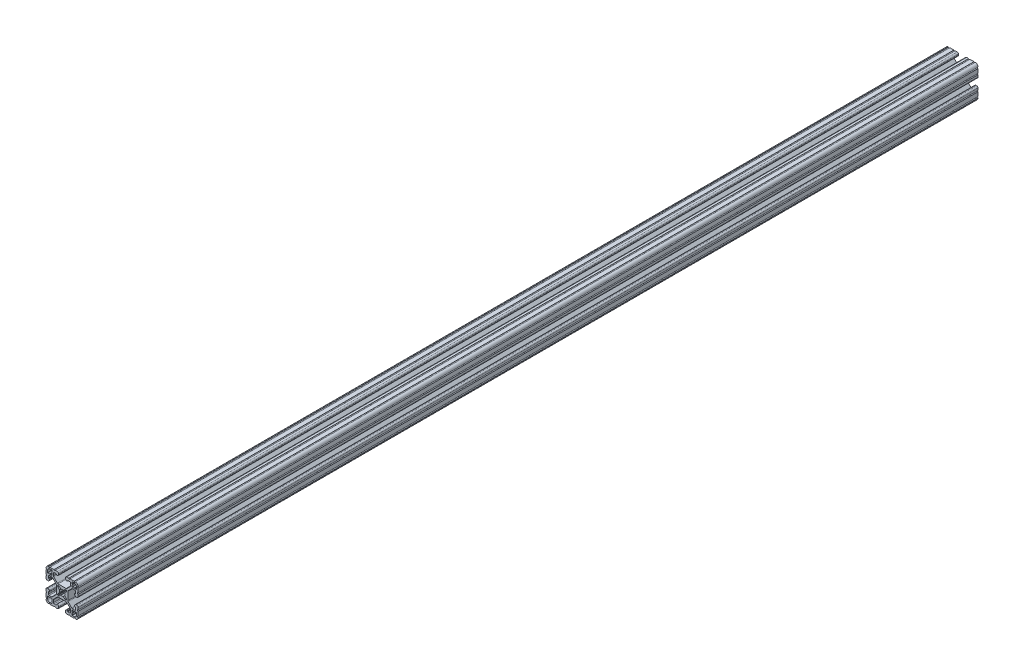
from build123d import *

# Parameters (mm, degrees)
BOSS_EXTRUDE1_DEPTH = 1066.8


with BuildPart() as part:
    # Sketch1 → Boss-Extrude1 (new body)
    with BuildSketch(Plane(origin=(0, 0, -2322.576), x_dir=(-1, 0, 0), z_dir=(0, 0, -1))):
        with BuildLine():
            Line((19.05, -14.325600033), (19.05, -9.4996))
            ThreePointArc((19.05, -9.4996), (18.288, -8.7376), (19.05, -7.9756))
            Line((19.05, -7.9756), (19.05, -5.6388))
            ThreePointArc((19.05, -5.6388), (18.588751759, -4.525248241), (17.4752, -4.064))
            Line((17.4752, -4.064), (16.5608, -4.064))
            ThreePointArc((16.5608, -4.064), (15.447248241, -4.525248241), (14.986, -5.6388))
            Line((14.986, -5.6388), (14.986, -6.350014224))
            ThreePointArc((14.986, -6.350014224), (15.097592316, -6.619421908), (15.367, -6.731014224))
            Line((15.367, -6.731014224), (15.6972, -6.731014224))
            ThreePointArc((15.6972, -6.731014224), (15.966607684, -6.84260654), (16.0782, -7.112014224))
            Line((16.0782, -7.112014224), (16.0782, -9.398014224))
            ThreePointArc((16.0782, -9.398014224), (15.817817928, -10.026632152), (15.1892, -10.287014224))
            Line((15.1892, -10.287014224), (12.375630013, -10.287014224))
            ThreePointArc((12.375630013, -10.287014224), (11.889622054, -10.19034123), (11.477604401, -9.915039836))
            Line((11.477604401, -9.915039836), (7.115699788, -5.553135223))
            ThreePointArc((7.115699788, -5.553135223), (6.840398394, -5.14111757), (6.7437254, -4.655109611))
            Line((6.7437254, -4.655109611), (6.7437254, 4.655109611))
            ThreePointArc((6.7437254, 4.655109611), (6.840398394, 5.14111757), (7.115699788, 5.553135223))
            Line((7.115699788, 5.553135223), (11.477604401, 9.915039836))
            ThreePointArc((11.477604401, 9.915039836), (11.889622054, 10.19034123), (12.375630013, 10.287014224))
            Line((12.375630013, 10.287014224), (15.1892, 10.287014224))
            ThreePointArc((15.1892, 10.287014224), (15.817817928, 10.026632152), (16.0782, 9.398014224))
            Line((16.0782, 9.398014224), (16.0782, 7.112014224))
            ThreePointArc((16.0782, 7.112014224), (15.966607684, 6.84260654), (15.6972, 6.731014224))
            Line((15.6972, 6.731014224), (15.367, 6.731014224))
            ThreePointArc((15.367, 6.731014224), (15.097592316, 6.619421908), (14.986, 6.350014224))
            Line((14.986, 6.350014224), (14.986, 5.6388))
            ThreePointArc((14.986, 5.6388), (15.447248241, 4.525248241), (16.5608, 4.064))
            Line((16.5608, 4.064), (17.4752, 4.064))
            ThreePointArc((17.4752, 4.064), (18.588751759, 4.525248241), (19.05, 5.6388))
            Line((19.05, 5.6388), (19.05, 7.9756))
            ThreePointArc((19.05, 7.9756), (18.288, 8.7376), (19.05, 9.4996))
            Line((19.05, 9.4996), (19.05, 14.325599984))
            ThreePointArc((19.05, 14.325599984), (18.287999986, 15.087549208), (19.049898416, 15.849600009))
            ThreePointArc((19.049898416, 15.849600009), (18.120064036, 18.120064058), (15.849599977, 19.049898414))
            ThreePointArc((15.849599977, 19.049898414), (15.0875492, 18.288000035), (14.325600017, 19.050000016))
            Line((14.325600017, 19.050000016), (9.499600001, 19.050000016))
            ThreePointArc((9.499600001, 19.050000016), (8.737600001, 18.288000016), (7.975600001, 19.050000016))
            Line((7.975600001, 19.050000016), (5.638800016, 19.050000016))
            ThreePointArc((5.638800016, 19.050000016), (4.525248257, 18.588751775), (4.064000016, 17.475200016))
            Line((4.064000016, 17.475200016), (4.064000016, 16.5608))
            ThreePointArc((4.064000016, 16.5608), (4.525248257, 15.447248241), (5.638800016, 14.986))
            Line((5.638800016, 14.986), (6.350014224, 14.986))
            ThreePointArc((6.350014224, 14.986), (6.619421908, 15.097592316), (6.731014224, 15.367))
            Line((6.731014224, 15.367), (6.731014224, 15.6972))
            ThreePointArc((6.731014224, 15.6972), (6.84260654, 15.966607684), (7.112014224, 16.0782))
            Line((7.112014224, 16.0782), (9.398014224, 16.0782))
            ThreePointArc((9.398014224, 16.0782), (10.026632152, 15.817817928), (10.287014224, 15.1892))
            Line((10.287014224, 15.1892), (10.287014224, 12.375630013))
            ThreePointArc((10.287014224, 12.375630013), (10.19034123, 11.889622054), (9.915039836, 11.477604401))
            Line((9.915039836, 11.477604401), (5.553135223, 7.115699788))
            ThreePointArc((5.553135223, 7.115699788), (5.14111757, 6.840398394), (4.655109611, 6.7437254))
            Line((4.655109611, 6.7437254), (-4.655109611, 6.7437254))
            ThreePointArc((-4.655109611, 6.7437254), (-5.14111757, 6.840398394), (-5.553135223, 7.115699788))
            Line((-5.553135223, 7.115699788), (-9.915039836, 11.477604401))
            ThreePointArc((-9.915039836, 11.477604401), (-10.19034123, 11.889622054), (-10.287014224, 12.375630013))
            Line((-10.287014224, 12.375630013), (-10.287014224, 15.1892))
            ThreePointArc((-10.287014224, 15.1892), (-10.026632152, 15.817817928), (-9.398014224, 16.0782))
            Line((-9.398014224, 16.0782), (-7.112014224, 16.0782))
            ThreePointArc((-7.112014224, 16.0782), (-6.84260654, 15.966607684), (-6.731014224, 15.6972))
            Line((-6.731014224, 15.6972), (-6.731014224, 15.367))
            ThreePointArc((-6.731014224, 15.367), (-6.619421908, 15.097592316), (-6.350014224, 14.986))
            Line((-6.350014224, 14.986), (-5.638799984, 14.986))
            ThreePointArc((-5.638799984, 14.986), (-4.525248225, 15.447248241), (-4.063999984, 16.5608))
            Line((-4.063999984, 16.5608), (-4.063999984, 17.475200016))
            ThreePointArc((-4.063999984, 17.475200016), (-4.525248225, 18.588751775), (-5.638799984, 19.050000016))
            Line((-5.638799984, 19.050000016), (-7.975599999, 19.050000016))
            ThreePointArc((-7.975599999, 19.050000016), (-8.737599999, 18.288000016), (-9.499599999, 19.050000016))
            Line((-9.499599999, 19.050000016), (-14.325599999, 19.050000016))
            ThreePointArc((-14.325599999, 19.050000016), (-15.087549199, 18.288000018), (-15.849599993, 19.049898416))
            ThreePointArc((-15.849599993, 19.049898416), (-18.120064042, 18.120064036), (-19.049898398, 15.849599976))
            ThreePointArc((-19.049898398, 15.849599976), (-18.288000019, 15.087549199), (-19.05, 14.325600017))
            Line((-19.05, 14.325600017), (-19.05, 9.4996))
            ThreePointArc((-19.05, 9.4996), (-18.288, 8.7376), (-19.05, 7.9756))
            Line((-19.05, 7.9756), (-19.05, 5.6388))
            ThreePointArc((-19.05, 5.6388), (-18.588751759, 4.525248241), (-17.4752, 4.064))
            Line((-17.4752, 4.064), (-16.5608, 4.064))
            ThreePointArc((-16.5608, 4.064), (-15.447248241, 4.525248241), (-14.986, 5.6388))
            Line((-14.986, 5.6388), (-14.986, 6.350014224))
            ThreePointArc((-14.986, 6.350014224), (-15.097592316, 6.619421908), (-15.367, 6.731014224))
            Line((-15.367, 6.731014224), (-15.6972, 6.731014224))
            ThreePointArc((-15.6972, 6.731014224), (-15.966607684, 6.84260654), (-16.0782, 7.112014224))
            Line((-16.0782, 7.112014224), (-16.0782, 9.398014224))
            ThreePointArc((-16.0782, 9.398014224), (-15.817817928, 10.026632152), (-15.1892, 10.287014224))
            Line((-15.1892, 10.287014224), (-12.375630013, 10.287014224))
            ThreePointArc((-12.375630013, 10.287014224), (-11.889622054, 10.19034123), (-11.477604401, 9.915039836))
            Line((-11.477604401, 9.915039836), (-7.115699788, 5.553135223))
            ThreePointArc((-7.115699788, 5.553135223), (-6.840398394, 5.14111757), (-6.7437254, 4.655109611))
            Line((-6.7437254, 4.655109611), (-6.7437254, -4.655109611))
            ThreePointArc((-6.7437254, -4.655109611), (-6.840398394, -5.14111757), (-7.115699788, -5.553135223))
            Line((-7.115699788, -5.553135223), (-11.477604401, -9.915039836))
            ThreePointArc((-11.477604401, -9.915039836), (-11.889622054, -10.19034123), (-12.375630013, -10.287014224))
            Line((-12.375630013, -10.287014224), (-15.1892, -10.287014224))
            ThreePointArc((-15.1892, -10.287014224), (-15.817817928, -10.026632152), (-16.0782, -9.398014224))
            Line((-16.0782, -9.398014224), (-16.0782, -7.112014224))
            ThreePointArc((-16.0782, -7.112014224), (-15.966607684, -6.84260654), (-15.6972, -6.731014224))
            Line((-15.6972, -6.731014224), (-15.367, -6.731014224))
            ThreePointArc((-15.367, -6.731014224), (-15.097592316, -6.619421908), (-14.986, -6.350014224))
            Line((-14.986, -6.350014224), (-14.986, -5.6388))
            ThreePointArc((-14.986, -5.6388), (-15.447248241, -4.525248241), (-16.5608, -4.064))
            Line((-16.5608, -4.064), (-17.4752, -4.064))
            ThreePointArc((-17.4752, -4.064), (-18.588751759, -4.525248241), (-19.05, -5.6388))
            Line((-19.05, -5.6388), (-19.05, -7.9756))
            ThreePointArc((-19.05, -7.9756), (-18.288, -8.7376), (-19.05, -9.4996))
            Line((-19.05, -9.4996), (-19.05, -14.3256))
            ThreePointArc((-19.05, -14.3256), (-18.288000002, -15.0875492), (-19.0498984, -15.849599993))
            ThreePointArc((-19.0498984, -15.849599993), (-18.120064019, -18.120064043), (-15.84959996, -19.049898399))
            ThreePointArc((-15.84959996, -19.049898399), (-15.087549183, -18.288000019), (-14.325600001, -19.050000001))
            Line((-14.325600001, -19.050000001), (-9.499599984, -19.050000001))
            ThreePointArc((-9.499599984, -19.050000001), (-8.737599984, -18.288000001), (-7.975599984, -19.050000001))
            Line((-7.975599984, -19.050000001), (-5.638799984, -19.050000001))
            ThreePointArc((-5.638799984, -19.050000001), (-4.525248225, -18.58875176), (-4.063999984, -17.475200001))
            Line((-4.063999984, -17.475200001), (-4.063999984, -16.5608))
            ThreePointArc((-4.063999984, -16.5608), (-4.525248225, -15.447248241), (-5.638799984, -14.986))
            Line((-5.638799984, -14.986), (-6.350014224, -14.986))
            ThreePointArc((-6.350014224, -14.986), (-6.619421908, -15.097592316), (-6.731014224, -15.367))
            Line((-6.731014224, -15.367), (-6.731014224, -15.6972))
            ThreePointArc((-6.731014224, -15.6972), (-6.84260654, -15.966607684), (-7.112014224, -16.0782))
            Line((-7.112014224, -16.0782), (-9.398014224, -16.0782))
            ThreePointArc((-9.398014224, -16.0782), (-10.026632152, -15.817817928), (-10.287014224, -15.1892))
            Line((-10.287014224, -15.1892), (-10.287014224, -12.375630013))
            ThreePointArc((-10.287014224, -12.375630013), (-10.19034123, -11.889622054), (-9.915039836, -11.477604401))
            Line((-9.915039836, -11.477604401), (-5.553135223, -7.115699788))
            ThreePointArc((-5.553135223, -7.115699788), (-5.14111757, -6.840398394), (-4.655109611, -6.7437254))
            Line((-4.655109611, -6.7437254), (4.655109611, -6.7437254))
            ThreePointArc((4.655109611, -6.7437254), (5.14111757, -6.840398394), (5.553135223, -7.115699788))
            Line((5.553135223, -7.115699788), (9.915039836, -11.477604401))
            ThreePointArc((9.915039836, -11.477604401), (10.19034123, -11.889622054), (10.287014224, -12.375630013))
            Line((10.287014224, -12.375630013), (10.287014224, -15.1892))
            ThreePointArc((10.287014224, -15.1892), (10.026632152, -15.817817928), (9.398014224, -16.0782))
            Line((9.398014224, -16.0782), (7.112014224, -16.0782))
            ThreePointArc((7.112014224, -16.0782), (6.84260654, -15.966607684), (6.731014224, -15.6972))
            Line((6.731014224, -15.6972), (6.731014224, -15.367))
            ThreePointArc((6.731014224, -15.367), (6.619421908, -15.097592316), (6.350014224, -14.986))
            Line((6.350014224, -14.986), (5.638800016, -14.986))
            ThreePointArc((5.638800016, -14.986), (4.525248257, -15.447248241), (4.064000016, -16.5608))
            Line((4.064000016, -16.5608), (4.064000016, -17.475200001))
            ThreePointArc((4.064000016, -17.475200001), (4.525248257, -18.58875176), (5.638800016, -19.050000001))
            Line((5.638800016, -19.050000001), (7.975600016, -19.050000001))
            ThreePointArc((7.975600016, -19.050000001), (8.737600016, -18.288000001), (9.499600016, -19.050000001))
            Line((9.499600016, -19.050000001), (14.325600016, -19.050000001))
            ThreePointArc((14.325600016, -19.050000001), (15.087549216, -18.288000002), (15.849600009, -19.0498984))
            ThreePointArc((15.849600009, -19.0498984), (18.120064059, -18.12006402), (19.049898415, -15.849599961))
            ThreePointArc((19.049898415, -15.849599961), (18.288000034, -15.087549207), (19.05, -14.325600033))
        make_face()
        with BuildLine():
            Line((17.246614224, 14.452614224), (17.246614224, 12.242814224))
            ThreePointArc((17.246614224, 12.242814224), (17.135021908, 11.97340654), (16.865614224, 11.861814224))
            Line((16.865614224, 11.861814224), (15.092694224, 11.861814224))
            Line((15.092694224, 11.861814224), (14.554214224, 12.400294224))
            Line((14.554214224, 12.400294224), (14.015734224, 11.861814224))
            Line((14.015734224, 11.861814224), (12.242814224, 11.861814224))
            ThreePointArc((12.242814224, 11.861814224), (11.97340654, 11.97340654), (11.861814224, 12.242814224))
            Line((11.861814224, 12.242814224), (11.861814224, 14.015734224))
            Line((11.861814224, 14.015734224), (12.400294224, 14.554214224))
            Line((12.400294224, 14.554214224), (11.861814224, 15.092694224))
            Line((11.861814224, 15.092694224), (11.861814224, 16.865614224))
            ThreePointArc((11.861814224, 16.865614224), (11.97340654, 17.135021908), (12.242814224, 17.246614224))
            Line((12.242814224, 17.246614224), (14.452614224, 17.246614224))
            ThreePointArc((14.452614224, 17.246614224), (16.428270571, 16.428270571), (17.246614224, 14.452614224))
        make_face(mode=Mode.SUBTRACT)
        with BuildLine():
            Line((17.246614224, -12.242814224), (17.246614224, -14.452614224))
            ThreePointArc((17.246614224, -14.452614224), (16.428270571, -16.428270571), (14.452614224, -17.246614224))
            Line((14.452614224, -17.246614224), (12.242814224, -17.246614224))
            ThreePointArc((12.242814224, -17.246614224), (11.97340654, -17.135021908), (11.861814224, -16.865614224))
            Line((11.861814224, -16.865614224), (11.861814224, -15.092694224))
            Line((11.861814224, -15.092694224), (12.400294224, -14.554214224))
            Line((12.400294224, -14.554214224), (11.861814224, -14.015734224))
            Line((11.861814224, -14.015734224), (11.861814224, -12.242814224))
            ThreePointArc((11.861814224, -12.242814224), (11.97340654, -11.97340654), (12.242814224, -11.861814224))
            Line((12.242814224, -11.861814224), (14.015734224, -11.861814224))
            Line((14.015734224, -11.861814224), (14.554214224, -12.400294224))
            Line((14.554214224, -12.400294224), (15.092694224, -11.861814224))
            Line((15.092694224, -11.861814224), (16.865614224, -11.861814224))
            ThreePointArc((16.865614224, -11.861814224), (17.135021908, -11.97340654), (17.246614224, -12.242814224))
        make_face(mode=Mode.SUBTRACT)
        with BuildLine():
            Line((5.1689, -3.920689755), (5.1689, -4.9149))
            ThreePointArc((5.1689, -4.9149), (5.094505122, -5.094505122), (4.9149, -5.1689))
            Line((4.9149, -5.1689), (3.920689755, -5.1689))
            ThreePointArc((3.920689755, -5.1689), (3.580484184, -5.101228904), (3.292071827, -4.908517928))
            Line((3.292071827, -4.908517928), (1.582347442, -3.198793543))
            ThreePointArc((1.582347442, -3.198793543), (1.393016011, -3.095711236), (1.178048687, -3.111879183))
            ThreePointArc((1.178048687, -3.111879183), (0, -3.3274), (-1.178048687, -3.111879183))
            ThreePointArc((-1.178048687, -3.111879183), (-1.393016011, -3.095711236), (-1.582347442, -3.198793543))
            Line((-1.582347442, -3.198793543), (-3.292071827, -4.908517928))
            ThreePointArc((-3.292071827, -4.908517928), (-3.580484184, -5.101228904), (-3.920689755, -5.1689))
            Line((-3.920689755, -5.1689), (-4.9149, -5.1689))
            ThreePointArc((-4.9149, -5.1689), (-5.094505122, -5.094505122), (-5.1689, -4.9149))
            Line((-5.1689, -4.9149), (-5.1689, -3.920689755))
            ThreePointArc((-5.1689, -3.920689755), (-5.101228904, -3.580484184), (-4.908517928, -3.292071827))
            Line((-4.908517928, -3.292071827), (-3.198793543, -1.582347442))
            ThreePointArc((-3.198793543, -1.582347442), (-3.095711236, -1.393016011), (-3.111879183, -1.178048687))
            ThreePointArc((-3.111879183, -1.178048687), (-3.3274, 0), (-3.111879183, 1.178048687))
            ThreePointArc((-3.111879183, 1.178048687), (-3.095711236, 1.393016011), (-3.198793543, 1.582347442))
            Line((-3.198793543, 1.582347442), (-4.908517928, 3.292071827))
            ThreePointArc((-4.908517928, 3.292071827), (-5.101228904, 3.580484184), (-5.1689, 3.920689755))
            Line((-5.1689, 3.920689755), (-5.1689, 4.9149))
            ThreePointArc((-5.1689, 4.9149), (-5.094505122, 5.094505122), (-4.9149, 5.1689))
            Line((-4.9149, 5.1689), (-3.920689755, 5.1689))
            ThreePointArc((-3.920689755, 5.1689), (-3.580484184, 5.101228904), (-3.292071827, 4.908517928))
            Line((-3.292071827, 4.908517928), (-1.582347442, 3.198793543))
            ThreePointArc((-1.582347442, 3.198793543), (-1.393016011, 3.095711236), (-1.178048687, 3.111879183))
            ThreePointArc((-1.178048687, 3.111879183), (0, 3.3274), (1.178048687, 3.111879183))
            ThreePointArc((1.178048687, 3.111879183), (1.393016011, 3.095711236), (1.582347442, 3.198793543))
            Line((1.582347442, 3.198793543), (3.292071827, 4.908517928))
            ThreePointArc((3.292071827, 4.908517928), (3.580484184, 5.101228904), (3.920689755, 5.1689))
            Line((3.920689755, 5.1689), (4.9149, 5.1689))
            ThreePointArc((4.9149, 5.1689), (5.094505122, 5.094505122), (5.1689, 4.9149))
            Line((5.1689, 4.9149), (5.1689, 3.920689755))
            ThreePointArc((5.1689, 3.920689755), (5.101228904, 3.580484184), (4.908517928, 3.292071827))
            Line((4.908517928, 3.292071827), (3.198793543, 1.582347442))
            ThreePointArc((3.198793543, 1.582347442), (3.095711236, 1.393016011), (3.111879183, 1.178048687))
            ThreePointArc((3.111879183, 1.178048687), (3.3274, 0), (3.111879183, -1.178048687))
            ThreePointArc((3.111879183, -1.178048687), (3.095711236, -1.393016011), (3.198793543, -1.582347442))
            Line((3.198793543, -1.582347442), (4.908517928, -3.292071827))
            ThreePointArc((4.908517928, -3.292071827), (5.101228904, -3.580484184), (5.1689, -3.920689755))
        make_face(mode=Mode.SUBTRACT)
        with BuildLine():
            Line((-11.861814224, -12.242814224), (-11.861814224, -14.015734224))
            Line((-11.861814224, -14.015734224), (-12.400294224, -14.554214224))
            Line((-12.400294224, -14.554214224), (-11.861814224, -15.092694224))
            Line((-11.861814224, -15.092694224), (-11.861814224, -16.865614224))
            ThreePointArc((-11.861814224, -16.865614224), (-11.97340654, -17.135021908), (-12.242814224, -17.246614224))
            Line((-12.242814224, -17.246614224), (-14.452614224, -17.246614224))
            ThreePointArc((-14.452614224, -17.246614224), (-16.428270571, -16.428270571), (-17.246614224, -14.452614224))
            Line((-17.246614224, -14.452614224), (-17.246614224, -12.242814224))
            ThreePointArc((-17.246614224, -12.242814224), (-17.135021908, -11.97340654), (-16.865614224, -11.861814224))
            Line((-16.865614224, -11.861814224), (-15.092694224, -11.861814224))
            Line((-15.092694224, -11.861814224), (-14.554214224, -12.400294224))
            Line((-14.554214224, -12.400294224), (-14.015734224, -11.861814224))
            Line((-14.015734224, -11.861814224), (-12.242814224, -11.861814224))
            ThreePointArc((-12.242814224, -11.861814224), (-11.97340654, -11.97340654), (-11.861814224, -12.242814224))
        make_face(mode=Mode.SUBTRACT)
        with BuildLine():
            Line((-11.861814224, 16.865614224), (-11.861814224, 15.092694224))
            Line((-11.861814224, 15.092694224), (-12.400294224, 14.554214224))
            Line((-12.400294224, 14.554214224), (-11.861814224, 14.015734224))
            Line((-11.861814224, 14.015734224), (-11.861814224, 12.242814224))
            ThreePointArc((-11.861814224, 12.242814224), (-11.97340654, 11.97340654), (-12.242814224, 11.861814224))
            Line((-12.242814224, 11.861814224), (-14.015734224, 11.861814224))
            Line((-14.015734224, 11.861814224), (-14.554214224, 12.400294224))
            Line((-14.554214224, 12.400294224), (-15.092694224, 11.861814224))
            Line((-15.092694224, 11.861814224), (-16.865614224, 11.861814224))
            ThreePointArc((-16.865614224, 11.861814224), (-17.135021908, 11.97340654), (-17.246614224, 12.242814224))
            Line((-17.246614224, 12.242814224), (-17.246614224, 14.452614224))
            ThreePointArc((-17.246614224, 14.452614224), (-16.428270571, 16.428270571), (-14.452614224, 17.246614224))
            Line((-14.452614224, 17.246614224), (-12.242814224, 17.246614224))
            ThreePointArc((-12.242814224, 17.246614224), (-11.97340654, 17.135021908), (-11.861814224, 16.865614224))
        make_face(mode=Mode.SUBTRACT)
    extrude(amount=-BOSS_EXTRUDE1_DEPTH)


solid = part.part
